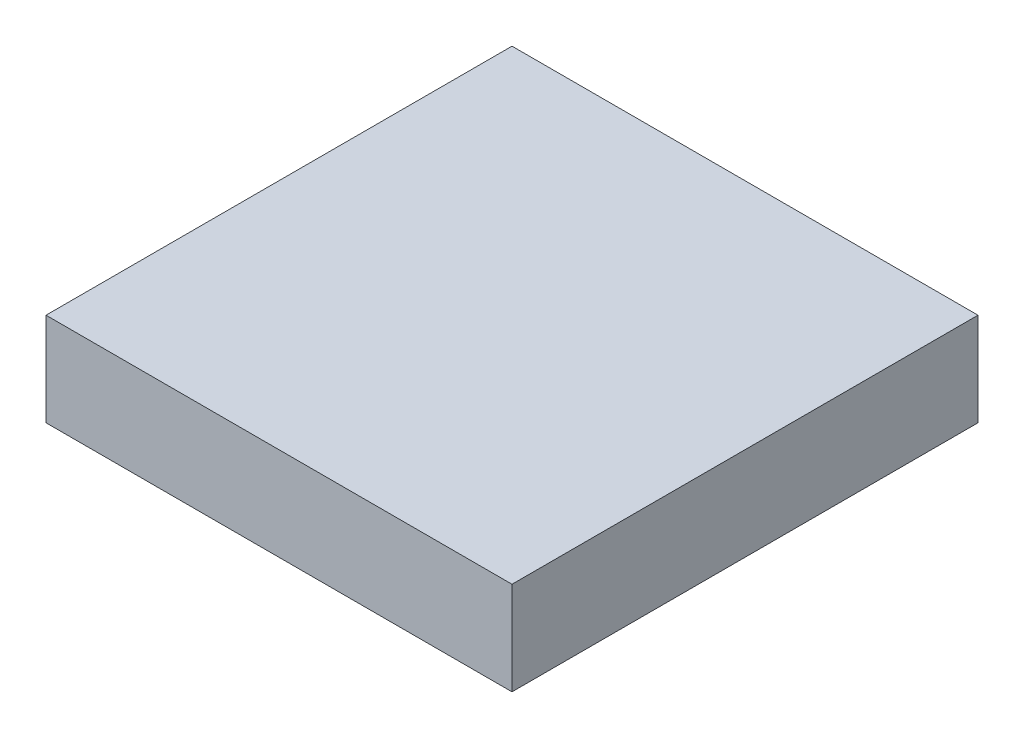
from build123d import *

# Parameters (mm, degrees)
SKETCH1_W           = 15
SKETCH1_H           = 15
BOSS_EXTRUDE1_DEPTH = 3
SKETCH2_W           = 12
SKETCH2_H           = 12
SKETCH2_R           = 2.5
CUT_EXTRUDE1_DEPTH  = 1.5
SKETCH3_R           = 0.75
CUT_EXTRUDE2_DEPTH  = 2


with BuildPart() as part:
    # Sketch1 → Boss-Extrude1 (new body)
    with BuildSketch(Plane(origin=(0, 0, 0), x_dir=(1, 0, 0), z_dir=(0, 1, 0))):
        Rectangle(SKETCH1_W, SKETCH1_H)
    extrude(amount=BOSS_EXTRUDE1_DEPTH)

    # Sketch2 → Cut-Extrude1 (cut)
    with BuildSketch(Plane.XZ):
        Rectangle(SKETCH2_W, SKETCH2_H)
        Circle(SKETCH2_R, mode=Mode.SUBTRACT)
    extrude(amount=-CUT_EXTRUDE1_DEPTH, mode=Mode.SUBTRACT)

    # Sketch3 → Cut-Extrude2 (cut)
    with BuildSketch(Plane.XZ):
        with Locations((-6.7, 6.7)):
            Circle(SKETCH3_R)
        with Locations((6.7, 6.7)):
            Circle(SKETCH3_R)
        with Locations((6.7, -6.7)):
            Circle(SKETCH3_R)
        with Locations((-6.7, -6.7)):
            Circle(SKETCH3_R)
    extrude(amount=-CUT_EXTRUDE2_DEPTH, mode=Mode.SUBTRACT)


solid = part.part
